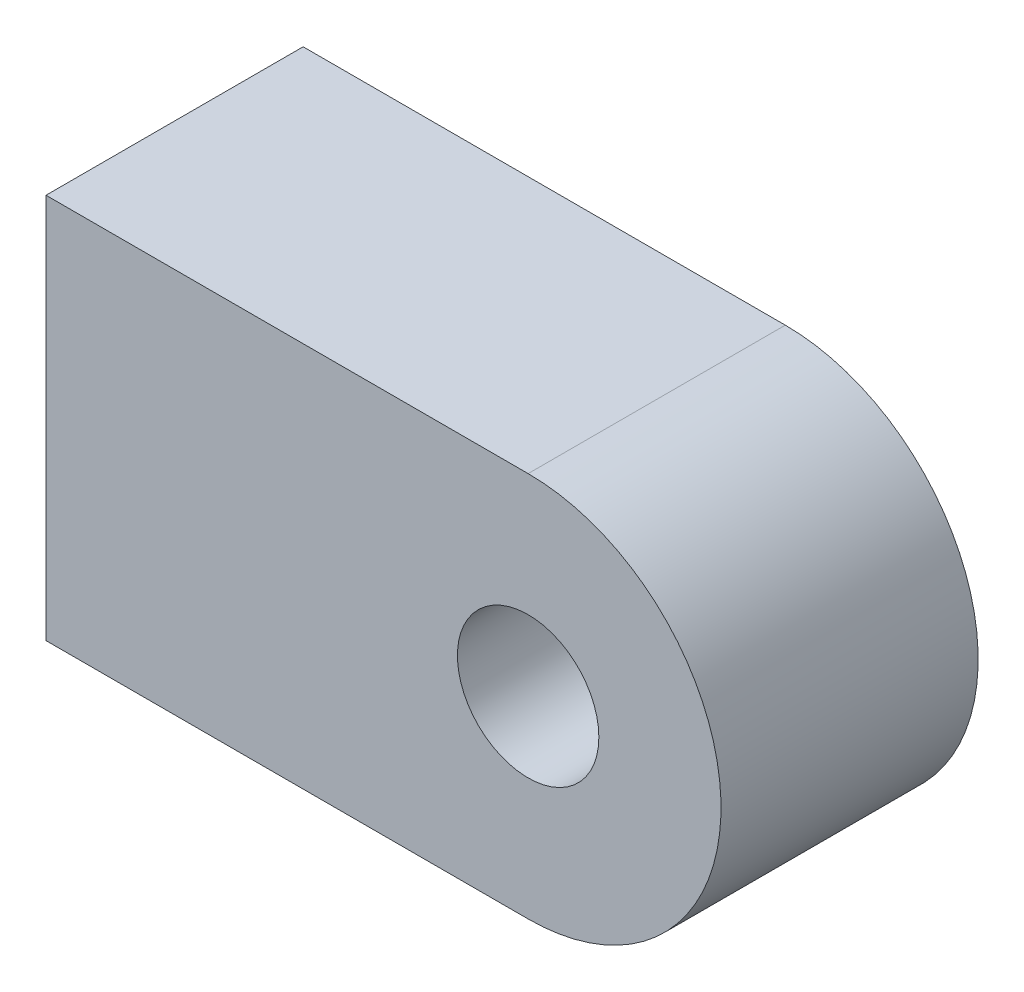
from build123d import *

# Parameters (mm, degrees)
SKIZZE1_R                       = 2.75
AUFSATZ_LINEAR_AUSTRAGEN1_DEPTH = 10


with BuildPart() as part:
    # Skizze1 → Aufsatz-Linear austragen1 (new body)
    with BuildSketch(Plane.XY):
        with BuildLine():
            Line((0, -7.5), (-18.75, -7.5))
            Line((-18.75, -7.5), (-18.75, 7.5))
            Line((-18.75, 7.5), (0, 7.5))
            ThreePointArc((0, 7.5), (7.5, 0), (0, -7.5))
        make_face()
        Circle(SKIZZE1_R, mode=Mode.SUBTRACT)
    extrude(amount=AUFSATZ_LINEAR_AUSTRAGEN1_DEPTH)


solid = part.part
